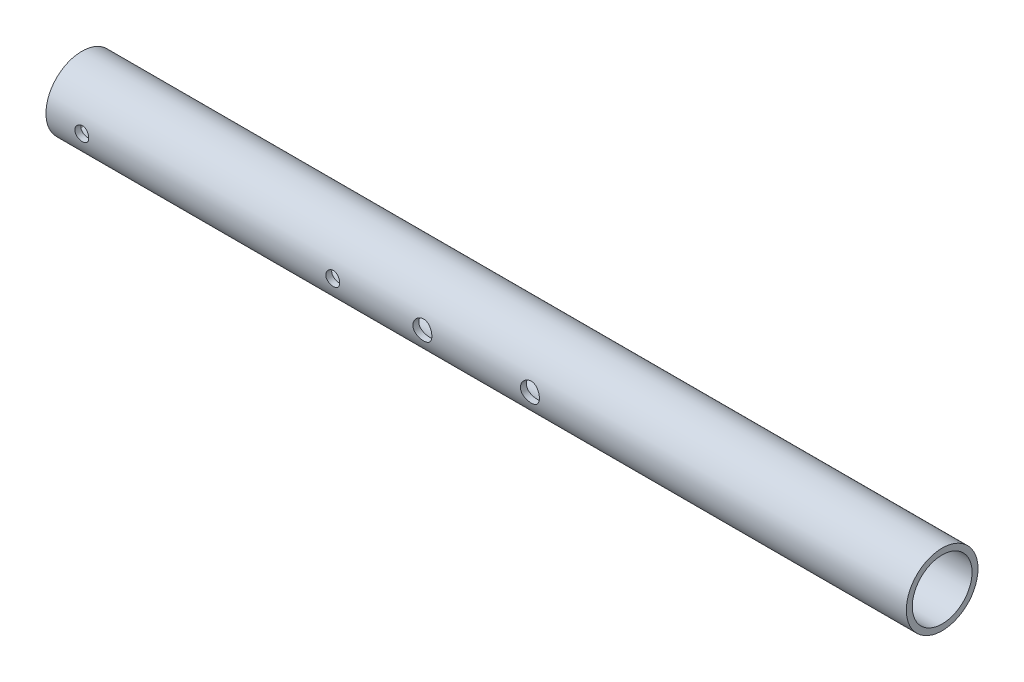
from build123d import *

# Parameters (mm, degrees)
SKETCH1_R               = 12.7
SKETCH1_R_2             = 10.5918
BOSS_EXTRUDE1_DEPTH     = 304.8
SKETCH8_R               = 2.4638
SKETCH8_R_2             = 3.3655
CUT_EXTRUDE1_DEPTH      = 13.7
CUT_EXTRUDE1_DEPTH_BACK = 13.7


with BuildPart() as part:
    # Sketch1 → Boss-Extrude1 (new body)
    with BuildSketch(Plane(origin=(0, 0, 0), x_dir=(0, 0, -1), z_dir=(1, 0, 0))):
        Circle(SKETCH1_R)
        Circle(SKETCH1_R_2, mode=Mode.SUBTRACT)
    extrude(amount=BOSS_EXTRUDE1_DEPTH)

    # Sketch8 → Cut-Extrude1 (cut, two sides)
    with BuildSketch(Plane.XY) as cut_extrude1_sk:
        with Locations((12.7, 0)):
            Circle(SKETCH8_R)
        with Locations((101.6, 0)):
            Circle(SKETCH8_R)
        with Locations((133.35, 0)):
            Circle(SKETCH8_R_2)
        with Locations((171.45, 0)):
            Circle(SKETCH8_R_2)
    extrude(amount=CUT_EXTRUDE1_DEPTH, mode=Mode.SUBTRACT)
    extrude(cut_extrude1_sk.sketch, amount=-CUT_EXTRUDE1_DEPTH_BACK, mode=Mode.SUBTRACT)


solid = part.part
